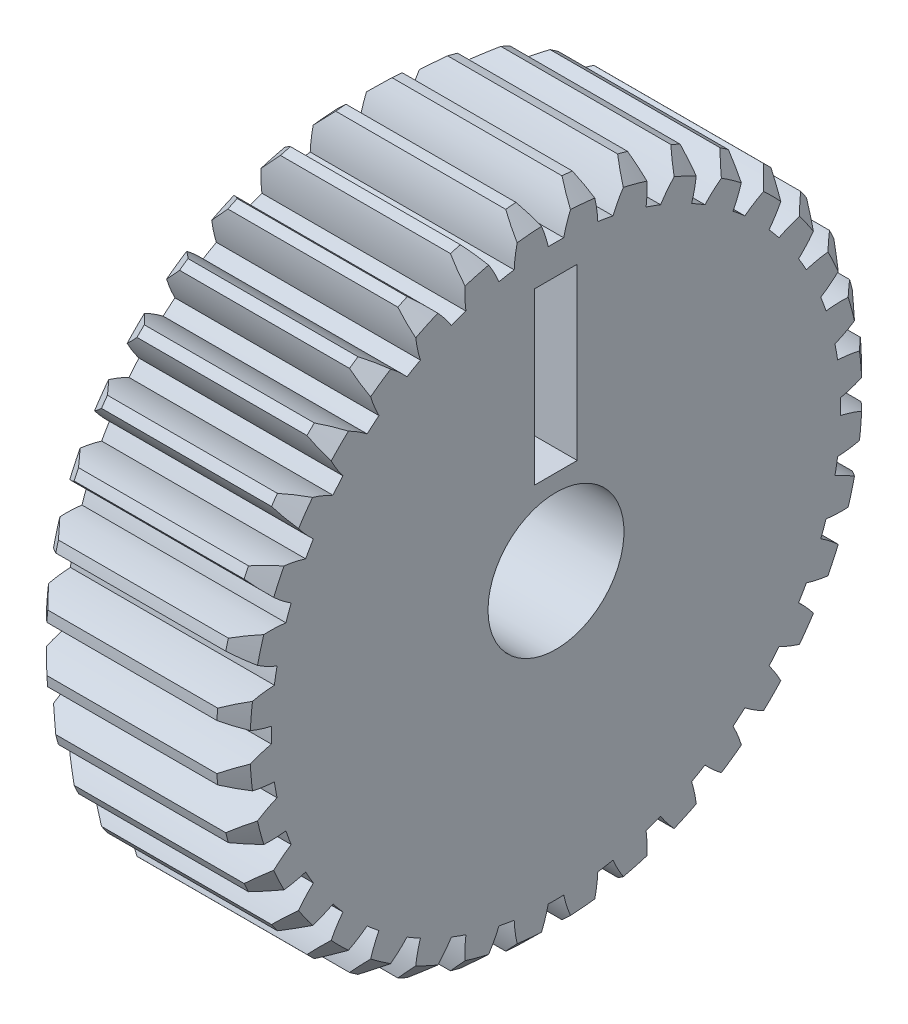
from build123d import *

# Parameters (mm, degrees)
BASPROSKE_W         = 12
BASPROSKE_H         = 19
CHAMFER1_SIZE       = 1
TOOTHCUT_DEPTH      = 13
TEETHCUTS_COUNT     = 36
TEETHCUTS_ANGLE     = 350
HUBNEAONESKE_R      = 7.5
HUBNEARONE_DEPTH    = 6.0024892
BORSKE_R            = 4
BORE_DEPTH          = 18.0024892
SKETCH2_W           = 2.5
SKETCH2_H           = 10
ROTATION_MARK_DEPTH = 5


with BuildPart() as part:
    # BasProSke → Base-Revolve (revolve)
    with BuildSketch(Plane(origin=(0, 0, 0), x_dir=(1, 0, 0), z_dir=(0, 1, 0))):
        with Locations((6, 9.5)):
            Rectangle(BASPROSKE_W, BASPROSKE_H)
    revolve(axis=Axis((-10, 0, 0), (1, 0, 0)))

    # Chamfer1
    chamfer1_edges = [part.edges().sort_by_distance(p)[0] for p in [
        (0, 0, 19),
        (12, 0, 19),
    ]]
    chamfer(chamfer1_edges, length=CHAMFER1_SIZE)

    # TooCutSke → ToothCut (cut, through all)
    with BuildSketch(Plane(origin=(0, 0, 0), x_dir=(0, 0, -1), z_dir=(1, 0, 0))):
        with BuildLine():
            ThreePointArc((0.454664826, 16.742827745), (0, 16.749), (-0.454664826, 16.742827745))
            ThreePointArc((-0.454664826, 16.742827745), (-0.817558311, 17.898033097), (-1.368909141, 18.976088452))
            ThreePointArc((-1.368909141, 18.976088452), (0, 19.0254), (1.368909141, 18.976088452))
            ThreePointArc((1.368909141, 18.976088452), (0.817558311, 17.898033097), (0.454664826, 16.742827745))
        make_face()
    toothcut = extrude(amount=TOOTHCUT_DEPTH, mode=Mode.SUBTRACT)

    # TeethCuts: ToothCut ×36 about axis
    teethcuts_axis = Axis((-10, 0, 0), (1, 0, 0))
    for i in range(1, TEETHCUTS_COUNT):
        add(toothcut.rotate(teethcuts_axis, i * TEETHCUTS_ANGLE / (TEETHCUTS_COUNT - 1)), mode=Mode.SUBTRACT)

    # HubNeaOneSke → HubNearOne (add)
    with BuildSketch(Plane.ZY):
        Circle(HUBNEAONESKE_R)
    extrude(amount=HUBNEARONE_DEPTH)

    # BorSke → Bore (cut, symmetric)
    with BuildSketch(Plane(origin=(0, 0, 0), x_dir=(0, 0, -1), z_dir=(1, 0, 0))):
        Circle(BORSKE_R)
    extrude(amount=BORE_DEPTH, both=True, mode=Mode.SUBTRACT)

    # Sketch2 → Rotation Mark (cut)
    with BuildSketch(Plane(origin=(12, 0, 0), x_dir=(0, 0, -1), z_dir=(1, 0, 0))):
        with Locations((0, 10)):
            Rectangle(SKETCH2_W, SKETCH2_H)
    extrude(amount=-ROTATION_MARK_DEPTH, mode=Mode.SUBTRACT)


solid = part.part
